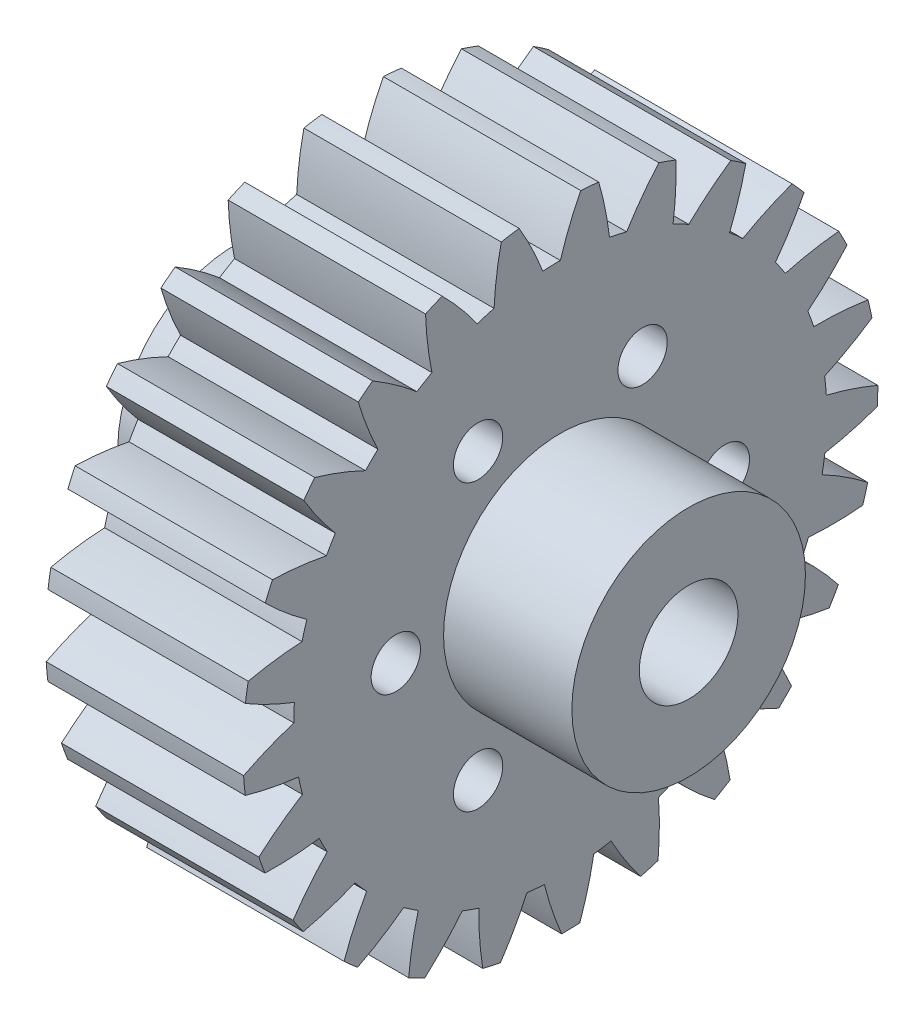
from build123d import *

# Parameters (mm, degrees)
SKETCH1_R                = 3
SKETCH1_R_2              = 1.5
BOSS_EXTRUDE1_DEPTH      = 12
SKETCH2_R                = 7.1
SKETCH2_R_2              = 3
BOSS_EXTRUDE2_DEPTH      = 7.8
BOSS_EXTRUDE2_DEPTH_BACK = 19.8


with BuildPart() as part:
    # Sketch1 → Boss-Extrude1 (new body)
    with BuildSketch(Plane(origin=(0, 0, 0), x_dir=(0, 0, -1), z_dir=(1, 0, 0))):
        with BuildLine():
            ThreePointArc((1.238674018, 19.260209933), (1.787037037, 19.217088714), (2.333948504, 19.158358082))
            ThreePointArc((2.333948504, 19.158358082), (2.729057328, 17.554121253), (2.987112235, 15.922222222))
            ThreePointArc((2.987112235, 15.922222222), (3.509848003, 15.81521315), (4.028776172, 15.69104721))
            ThreePointArc((4.028776172, 15.69104721), (4.952934471, 17.060579328), (5.989578231, 18.347069319))
            ThreePointArc((5.989578231, 18.347069319), (6.509989606, 18.168930495), (7.02511313, 17.976033642))
            ThreePointArc((7.02511313, 17.976033642), (7.008851408, 16.323937295), (6.852962259, 14.679131727))
            ThreePointArc((6.852962259, 14.679131727), (7.332663248, 14.445485443), (7.80440952, 14.196168217))
            ThreePointArc((7.80440952, 14.196168217), (9.040122475, 15.292845141), (10.364135216, 16.281114864))
            ThreePointArc((10.364135216, 16.281114864), (10.823895586, 15.979151552), (11.274864061, 15.664208898))
            ThreePointArc((11.274864061, 15.664208898), (10.848253576, 14.068060322), (10.288215461, 12.5136974))
            ThreePointArc((10.288215461, 12.5136974), (10.694740293, 12.168094759), (11.089663116, 11.809291764))
            ThreePointArc((11.089663116, 11.809291764), (12.559286337, 12.564205251), (14.087475468, 13.192158085))
            ThreePointArc((14.087475468, 13.192158085), (14.457696399, 12.785343751), (14.816173817, 12.3681443))
            ThreePointArc((14.816173817, 12.3681443), (14.006020076, 10.92823538), (13.077022248, 9.561981443))
            ThreePointArc((13.077022248, 9.561981443), (13.384827473, 9.12613793), (13.678112393, 8.680394079))
            ThreePointArc((13.678112393, 8.680394079), (15.289304048, 9.046110138), (16.925647827, 9.274289495))
            ThreePointArc((16.925647827, 9.274289495), (17.183066976, 8.78818578), (17.426528882, 8.294943709))
            ThreePointArc((17.426528882, 8.294943709), (16.283736823, 7.101749217), (15.044151634, 6.009451025))
            ThreePointArc((15.044151634, 6.009451025), (15.233896717, 5.510752291), (15.407115564, 5.006075309))
            ThreePointArc((15.407115564, 5.006075309), (17.058638555, 4.959614655), (18.700319484, 4.773683188))
            ThreePointArc((18.700319484, 4.773683188), (18.828762259, 4.238833776), (18.941911047, 3.700541298))
            ThreePointArc((18.941911047, 3.700541298), (17.538286499, 2.829034033), (16.066001643, 2.079324699))
            ThreePointArc((16.066001643, 2.079324699), (16.125764204, 1.549105818), (16.168033001, 1.017206416))
            ThreePointArc((16.168033001, 1.017206416), (17.756116065, 0.561488343), (19.299981294, -0.02687119))
            ThreePointArc((19.299981294, -0.02687119), (19.291377163, -0.576859743), (19.267103277, -1.126379733))
            ThreePointArc((19.267103277, -1.126379733), (17.690841132, -1.621439764), (16.078365683, -1.981453246))
            ThreePointArc((16.078365683, -1.981453246), (16.004390619, -2.50987667), (15.913053462, -3.035577296))
            ThreePointArc((15.913053462, -3.035577296), (17.3379115, -3.871918347), (18.686954298, -4.825737152))
            ThreePointArc((18.686954298, -4.825737152), (18.54184389, -5.356307044), (18.381672549, -5.882526182))
            ThreePointArc((18.381672549, -5.882526182), (16.731815155, -5.970032537), (15.080466875, -5.917729196))
            ThreePointArc((15.080466875, -5.917729196), (14.877402312, -6.411154376), (14.65819825, -6.897624523))
            ThreePointArc((14.65819825, -6.897624523), (15.830302192, -8.062038167), (16.899757238, -9.321384302))
            ThreePointArc((16.899757238, -9.321384302), (16.627258374, -9.799197873), (16.341253732, -10.269051877))
            ThreePointArc((16.341253732, -10.269051877), (14.721467697, -9.94350621), (13.135006871, -9.482172457))
            ThreePointArc((13.135006871, -9.482172457), (12.815612103, -9.909595675), (12.482314533, -10.326268634))
            ThreePointArc((12.482314533, -10.326268634), (13.328016776, -11.745590479), (14.050686278, -13.231334594))
            ThreePointArc((14.050686278, -13.231334594), (13.667921063, -13.626369062), (13.274053844, -14.010335276))
            ThreePointArc((13.274053844, -14.010335276), (11.786116281, -13.292192818), (10.364226078, -12.450815949))
            ThreePointArc((10.364226078, -12.450815949), (9.948569852, -12.785380632), (9.522121087, -13.106075309))
            ThreePointArc((9.522121087, -13.106075309), (9.98828305, -14.691124143), (10.318759024, -16.309911472))
            ThreePointArc((10.318759024, -16.309911472), (9.849778005, -16.597345367), (9.372796334, -16.871297783))
            ThreePointArc((9.372796334, -16.871297783), (8.110199833, -15.805682066), (6.942222843, -14.637128885))
            ThreePointArc((6.942222843, -14.637128885), (6.456422369, -14.857813103), (5.963617753, -15.062379071))
            ThreePointArc((5.963617753, -15.062379071), (6.020948765, -16.713560448), (5.938466191, -18.363676628))
            ThreePointArc((5.938466191, -18.363676628), (5.41273717, -18.525449423), (4.88261156, -18.672174602))
            ThreePointArc((4.88261156, -18.672174602), (3.924689702, -17.32604218), (3.084014216, -15.903737181))
            ThreePointArc((3.084014216, -15.903737181), (2.558594124, -15.996674533), (2.030398384, -16.072258161))
            ThreePointArc((2.030398384, -16.072258161), (1.675296126, -17.685822281), (1.185037687, -19.263584445))
            ThreePointArc((1.185037687, -19.263584445), (0.635594152, -19.28953136), (0.085634345, -19.299810019))
            ThreePointArc((0.085634345, -19.299810019), (-0.507423117, -17.757743344), (-0.967974366, -16.17105518))
            ThreePointArc((-0.967974366, -16.17105518), (-1.5, -16.130406071), (-2.030398384, -16.072258161))
            ThreePointArc((-2.030398384, -16.072258161), (-2.77562153, -17.546818857), (-3.642851094, -18.953090405))
            ThreePointArc((-3.642851094, -18.953090405), (-4.181485584, -18.841581099), (-4.716723591, -18.714767393))
            ThreePointArc((-4.716723591, -18.714767393), (-4.907652675, -17.073660185), (-4.95914156, -15.422286309))
            ThreePointArc((-4.95914156, -15.422286309), (-5.464343607, -15.250604871), (-5.963617753, -15.062379071))
            ThreePointArc((-5.963617753, -15.062379071), (-7.052136677, -16.305284271), (-8.241846142, -17.45170399))
            ThreePointArc((-8.241846142, -17.45170399), (-8.735827203, -17.209745003), (-9.222712438, -16.953807103))
            ThreePointArc((-9.222712438, -16.953807103), (-8.999516367, -15.316776164), (-8.63870765, -13.70447847))
            ThreePointArc((-8.63870765, -13.70447847), (-9.085342409, -13.41255208), (-9.522121087, -13.106075309))
            ThreePointArc((-9.522121087, -13.106075309), (-10.885540141, -14.039228708), (-12.322975686, -14.853762831))
            ThreePointArc((-12.322975686, -14.853762831), (-12.74126467, -14.496557336), (-13.149204342, -14.127576762))
            ThreePointArc((-13.149204342, -14.127576762), (-12.525907347, -12.597482765), (-11.775471968, -11.125567847))
            ThreePointArc((-11.775471968, -11.125567847), (-12.135475734, -10.731739314), (-12.482314533, -10.326268634))
            ThreePointArc((-12.482314533, -10.326268634), (-14.034965084, -10.891036772), (-15.629807347, -11.322505125))
            ThreePointArc((-15.629807347, -11.322505125), (-15.946121619, -10.872497657), (-16.249483379, -10.413658815))
            ThreePointArc((-16.249483379, -10.413658815), (-15.265249501, -9.086643194), (-14.172340075, -7.84759688))
            ThreePointArc((-14.172340075, -7.84759688), (-14.423092487, -7.376611898), (-14.65819825, -6.897624523))
            ThreePointArc((-14.65819825, -6.897624523), (-16.302521553, -7.058520942), (-17.95456073, -7.07981278))
            ThreePointArc((-17.95456073, -7.07981278), (-18.149025101, -6.565278964), (-18.328747614, -6.045412386))
            ThreePointArc((-18.328747614, -6.045412386), (-17.045419888, -5.004856413), (-15.678707933, -4.076532539))
            ThreePointArc((-15.678707933, -4.076532539), (-15.804453295, -3.557984828), (-15.913053462, -3.035577296))
            ThreePointArc((-15.913053462, -3.035577296), (-17.545730637, -2.782492281), (-19.15116303, -2.392269761))
            ThreePointArc((-19.15116303, -2.392269761), (-19.211558589, -1.845539648), (-19.256349227, -1.297310463))
            ThreePointArc((-19.256349227, -1.297310463), (-17.754563855, -0.608596097), (-16.19992491, -0.049324666))
            ThreePointArc((-16.19992491, -0.049324666), (-16.192762178, 0.484203515), (-16.168033001, 1.017206416))
            ThreePointArc((-16.168033001, 1.017206416), (-17.686476936, 1.668370603), (-19.144427324, 2.445588366))
            ThreePointArc((-19.144427324, 2.445588366), (-19.066959195, 2.990161712), (-18.974003599, 3.532306247))
            ThreePointArc((-18.974003599, 3.532306247), (-17.348123278, 3.82590455), (-15.703241025, 3.980982457))
            ThreePointArc((-15.703241025, 3.980982457), (-15.56362026, 4.49596757), (-15.407115564, 5.006075309))
            ThreePointArc((-15.407115564, 5.006075309), (-16.715916843, 6.014403626), (-17.93477684, 7.129781181))
            ThreePointArc((-17.93477684, 7.129781181), (-17.724312631, 7.637980214), (-17.499451543, 8.139975165))
            ThreePointArc((-17.499451543, 8.139975165), (-15.851636313, 8.020009544), (-14.219864754, 7.761149811))
            ThreePointArc((-14.219864754, 7.761149811), (-13.956558843, 8.225233448), (-13.678112393, 8.680394079))
            ThreePointArc((-13.678112393, 8.680394079), (-14.695034218, 9.98252955), (-15.598218369, 11.365983623))
            ThreePointArc((-15.598218369, 11.365983623), (-15.26798232, 11.805876329), (-14.925344588, 12.236179507))
            ThreePointArc((-14.925344588, 12.236179507), (-13.35913274, 11.710187842), (-11.843002083, 11.053655579))
            ThreePointArc((-11.843002083, 11.053655579), (-11.472555504, 11.437677658), (-11.089663116, 11.809291764))
            ThreePointArc((-11.089663116, 11.809291764), (-11.750808548, 13.323416429), (-12.281566471, 14.888019513))
            ThreePointArc((-12.281566471, 14.888019513), (-11.852308527, 15.231965815), (-11.413423341, 15.563539688))
            ThreePointArc((-11.413423341, 15.563539688), (-10.027225727, 14.664571972), (-8.722000036, 13.651619515))
            ThreePointArc((-8.722000036, 13.651619515), (-8.26768931, 13.931450516), (-7.80440952, 14.196168217))
            ThreePointArc((-7.80440952, 14.196168217), (-8.068236361, 15.827144054), (-8.193218583, 17.474586383))
            ThreePointArc((-8.193218583, 17.474586383), (-7.6919106, 17.700974869), (-7.18435473, 17.912985433))
            ThreePointArc((-7.18435473, 17.912985433), (-6.065271243, 16.697527111), (-5.05296265, 15.391801989))
            ThreePointArc((-5.05296265, 15.391801989), (-4.543333791, 15.549859101), (-4.028776172, 15.69104721))
            ThreePointArc((-4.028776172, 15.69104721), (-3.878707211, 17.33639401), (-3.590060639, 18.963160723))
            ThreePointArc((-3.590060639, 18.963160723), (-3.048201641, 19.057766573), (-2.503866689, 19.136892423))
            ThreePointArc((-2.503866689, 19.136892423), (-1.72221346, 17.681315214), (-1.066429036, 16.164860937))
            ThreePointArc((-1.066429036, 16.164860937), (-0.5335039, 16.191212851), (0, 16.2))
            ThreePointArc((0, 16.2), (0.554535379, 17.756334571), (1.238674018, 19.260209933))
        make_face()
        Circle(SKETCH1_R, mode=Mode.SUBTRACT)
        with Locations((10, 0)):
            Circle(SKETCH1_R_2, mode=Mode.SUBTRACT)
        with Locations((5, -8.660254038)):
            Circle(SKETCH1_R_2, mode=Mode.SUBTRACT)
        with Locations((-5, -8.660254038)):
            Circle(SKETCH1_R_2, mode=Mode.SUBTRACT)
        with Locations((-10, 0)):
            Circle(SKETCH1_R_2, mode=Mode.SUBTRACT)
        with Locations((-5, 8.660254038)):
            Circle(SKETCH1_R_2, mode=Mode.SUBTRACT)
        with Locations((5, 8.660254038)):
            Circle(SKETCH1_R_2, mode=Mode.SUBTRACT)
    extrude(amount=BOSS_EXTRUDE1_DEPTH)

    # Sketch2 → Boss-Extrude2 (add, two sides)
    with BuildSketch(Plane(origin=(12, 0, 0), x_dir=(0, 0, -1), z_dir=(1, 0, 0))) as boss_extrude2_sk:
        Circle(SKETCH2_R)
        Circle(SKETCH2_R_2, mode=Mode.SUBTRACT)
    extrude(amount=BOSS_EXTRUDE2_DEPTH)
    extrude(boss_extrude2_sk.sketch, amount=-BOSS_EXTRUDE2_DEPTH_BACK)


solid = part.part
